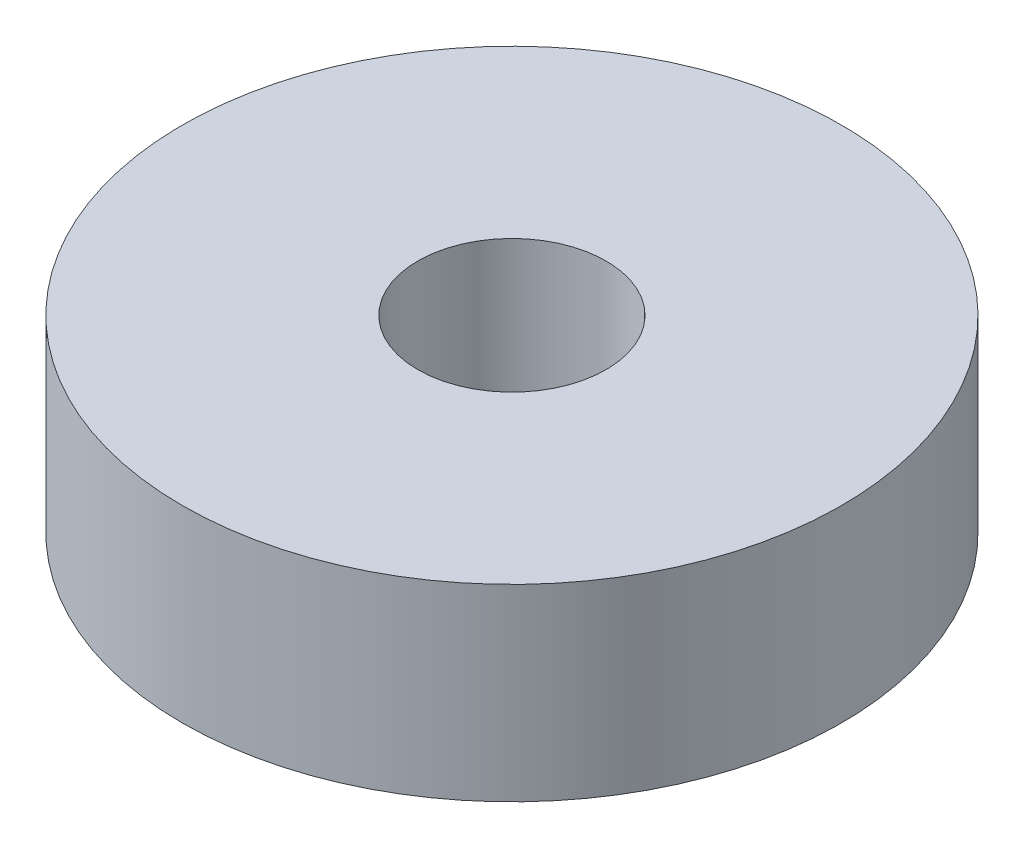
from build123d import *

# Parameters (mm, degrees)
SKETCH_1_R      = 7
SKETCH_1_R_2    = 2
EXTRUDE_1_DEPTH = 4


with BuildPart() as part:
    # 草图1 → 凸台-拉伸1 (new body)
    with BuildSketch(Plane(origin=(0, 0, 0), x_dir=(1, 0, 0), z_dir=(0, 1, 0))):
        Circle(SKETCH_1_R)
        Circle(SKETCH_1_R_2, mode=Mode.SUBTRACT)
    extrude(amount=EXTRUDE_1_DEPTH)


solid = part.part
